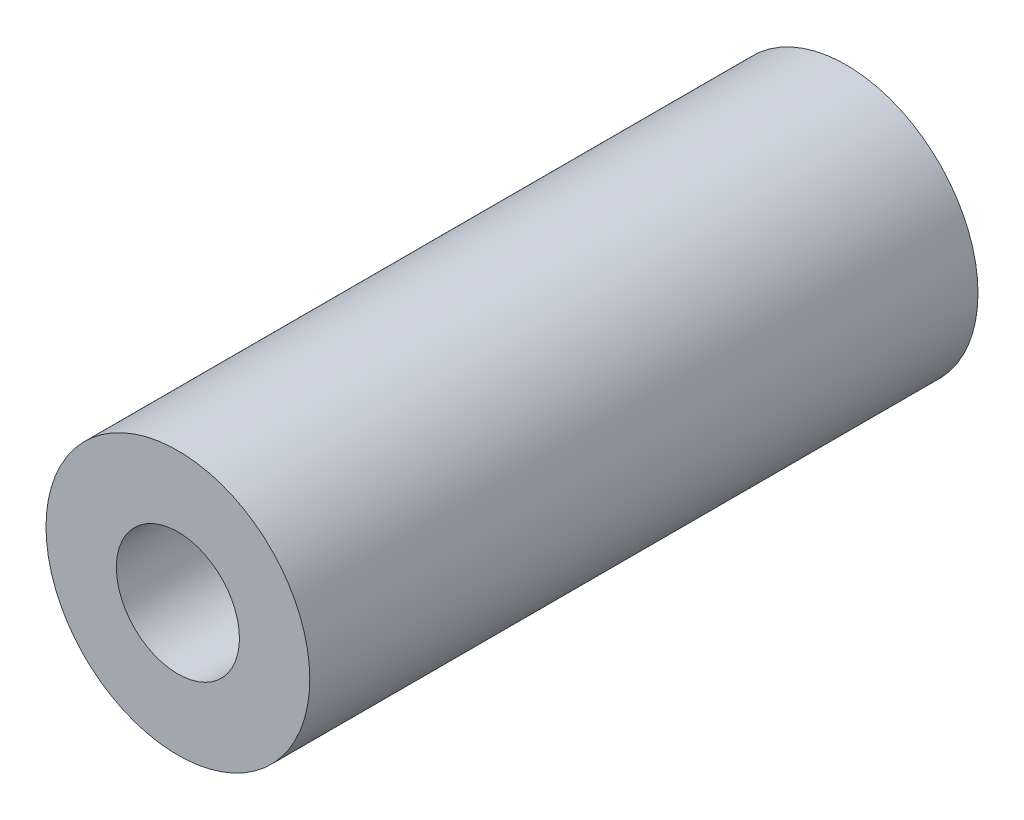
from build123d import *

# Parameters (mm, degrees)
SKETCH1_R           = 3.75
SKETCH1_R_2         = 1.75
BOSS_EXTRUDE1_DEPTH = 19


with BuildPart() as part:
    # Sketch1 → Boss-Extrude1 (new body)
    with BuildSketch(Plane.XY):
        Circle(SKETCH1_R)
        Circle(SKETCH1_R_2, mode=Mode.SUBTRACT)
    extrude(amount=BOSS_EXTRUDE1_DEPTH)


solid = part.part
